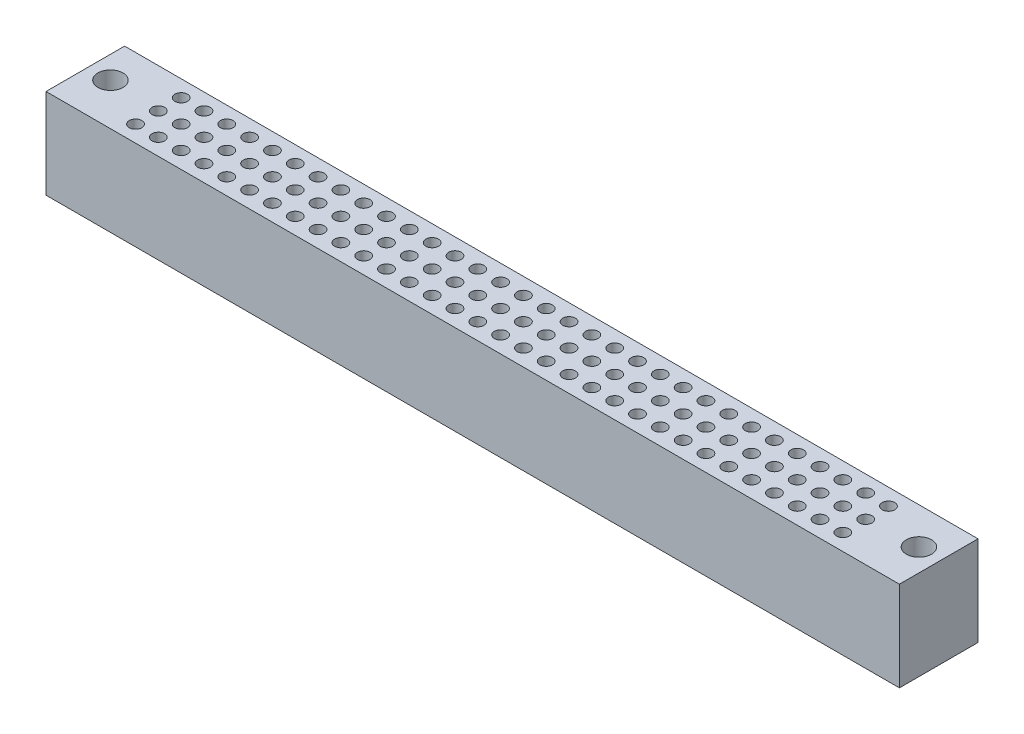
from build123d import *

# Parameters (mm, degrees)
SKETCH1_W                  = 95
SKETCH1_H                  = 8.75
BOSS_EXTRUDE1_DEPTH        = 10
F_2_8_2_8_DIAMETER_HOLE1_D = 2.8
F_1_4_1_4_DIAMETER_HOLE1_D = 1.4
LPATTERN1_COUNT            = 32
LPATTERN1_PITCH            = 2.54


with BuildPart() as part:
    # Sketch1 → Boss-Extrude1 (new body)
    with BuildSketch(Plane(origin=(0, 0, 0), x_dir=(1, 0, 0), z_dir=(0, 1, 0))):
        Rectangle(SKETCH1_W, SKETCH1_H)
    extrude(amount=BOSS_EXTRUDE1_DEPTH)

    # Ø2.8 (2.8) Diameter Hole1 (through all)
    with Locations(Plane(origin=(-45, 10, -0.3), x_dir=(0, 0, 1), z_dir=(0, 1, 0))):
        with Locations((0, 0), (0, 90)):
            Hole(F_2_8_2_8_DIAMETER_HOLE1_D / 2)

    # Ø1.4 (1.4) Diameter Hole1 (through all)
    with Locations(Plane(origin=(-39.37, 10, -2.54), x_dir=(0, 0, 1), z_dir=(0, 1, 0))):
        with Locations((0, 0), (2.54, 0), (5.08, 0)):
            f_1_4_1_4_diameter_hole1 = Hole(F_1_4_1_4_DIAMETER_HOLE1_D / 2)

    # LPattern1: Ø1.4 (1.4) Diameter Hole1 ×32
    with Locations(*[(i * LPATTERN1_PITCH, 0, 0) for i in range(1, LPATTERN1_COUNT)]):
        add(f_1_4_1_4_diameter_hole1, mode=Mode.SUBTRACT)


solid = part.part
